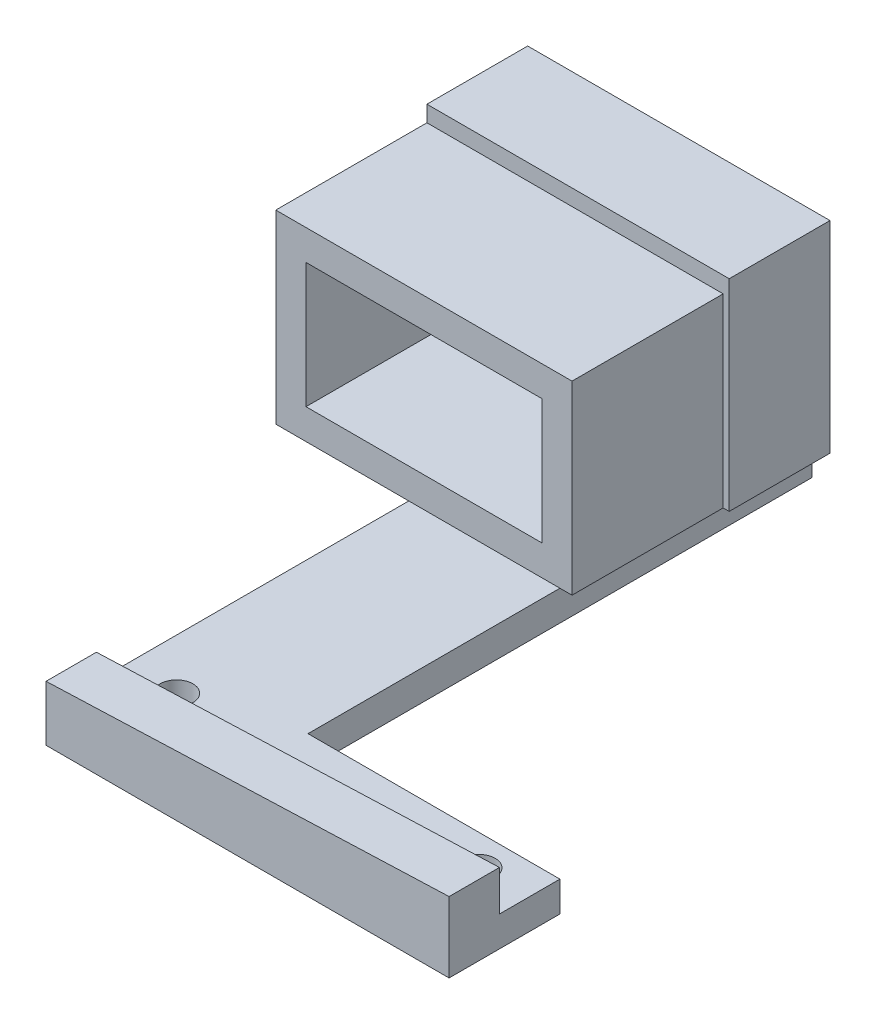
from build123d import *

# Parameters (mm, degrees)
ESQUISSE1_W             = 40
ESQUISSE1_H             = 7
BOSS_EXTRU_1_DEPTH      = 5
ENL_V_MAT_EXTRU_2_DEPTH = 6
ESQUISSE4_W             = 40
ESQUISSE4_H             = 3
BOSS_EXTRU_2_DEPTH      = 6
ESQUISSE5_R             = 1.625
ENL_V_MAT_EXTRU_3_DEPTH = 6
ESQUISSE6_W             = 15
ESQUISSE6_H             = 3
BOSS_EXTRU_3_DEPTH      = 50
ESQUISSE7_W             = 10
ESQUISSE7_H             = 3
BOSS_EXTRU_4_DEPTH      = 13.2
ESQUISSE8_W             = 30
ESQUISSE8_H             = 10
BOSS_EXTRU_5_DEPTH      = 20
ESQUISSE9_W             = 29.4
ESQUISSE9_H             = 18.4
ESQUISSE9_W_2           = 23.4
ESQUISSE9_H_2           = 12.4
BOSS_EXTRU_6_DEPTH      = 15
ESQUISSE11_W            = 10
ESQUISSE11_H            = 5
ENL_V_MAT_EXTRU_5_DEPTH = 15


with BuildPart() as part:
    # Esquisse1 → Boss.-Extru.1 (new body)
    with BuildSketch(Plane.XY):
        with Locations((20, -3.5)):
            Rectangle(ESQUISSE1_W, ESQUISSE1_H)
    extrude(amount=BOSS_EXTRU_1_DEPTH)

    # Esquisse3 → Enlèv. mat.-Extru.2 (cut, through all)
    with BuildSketch(Plane.XY.offset(5)):
        Polygon((40, 0), (0, 0), (0, -1.5), align=None)
    extrude(amount=-ENL_V_MAT_EXTRU_2_DEPTH, mode=Mode.SUBTRACT)

    # Esquisse4 → Boss.-Extru.2 (add)
    with BuildSketch(Plane(origin=(0, 0, 0), x_dir=(-1, 0, 0), z_dir=(0, 0, -1))):
        with Locations((-20, -5.5)):
            Rectangle(ESQUISSE4_W, ESQUISSE4_H)
    extrude(amount=BOSS_EXTRU_2_DEPTH)

    # Esquisse5 → Enlèv. mat.-Extru.3 (cut)
    with BuildSketch(Plane(origin=(0, -4, 0), x_dir=(1, 0, 0), z_dir=(0, 1, 0))):
        with Locations((35, 2.949699752)):
            Circle(ESQUISSE5_R)
        with Locations((5, 2.949699752)):
            Circle(ESQUISSE5_R)
    extrude(amount=-ENL_V_MAT_EXTRU_3_DEPTH, mode=Mode.SUBTRACT)

    # Esquisse6 → Boss.-Extru.3 (add)
    with BuildSketch(Plane(origin=(0, 0, -6), x_dir=(-1, 0, 0), z_dir=(0, 0, -1))):
        with Locations((-7.5, -5.5)):
            Rectangle(ESQUISSE6_W, ESQUISSE6_H)
    extrude(amount=BOSS_EXTRU_3_DEPTH)

    # Esquisse7 → Boss.-Extru.4 (add)
    with BuildSketch(Plane.ZY):
        with Locations((-51, -5.5)):
            Rectangle(ESQUISSE7_W, ESQUISSE7_H)
    extrude(amount=BOSS_EXTRU_4_DEPTH)

    # Esquisse8 → Boss.-Extru.5 (add)
    with BuildSketch(Plane(origin=(0, -4, 0), x_dir=(1, 0, 0), z_dir=(0, 1, 0))):
        with Locations((1.8, 51)):
            Rectangle(ESQUISSE8_W, ESQUISSE8_H)
    extrude(amount=BOSS_EXTRU_5_DEPTH)

    # Esquisse9 → Boss.-Extru.6 (add)
    with BuildSketch(Plane.XY.offset(-46)):
        with Locations((1.5, 5.2)):
            Rectangle(ESQUISSE9_W, ESQUISSE9_H)
        with Locations((1.5, 5.2)):
            Rectangle(ESQUISSE9_W_2, ESQUISSE9_H_2, mode=Mode.SUBTRACT)
    extrude(amount=BOSS_EXTRU_6_DEPTH)

    # Esquisse11 → Enlèv. mat.-Extru.5 (cut)
    with BuildSketch(Plane(origin=(0, 0, -56), x_dir=(-1, 0, 0), z_dir=(0, 0, -1))):
        with Locations((8.2, 5.5)):
            Rectangle(ESQUISSE11_W, ESQUISSE11_H)
    extrude(amount=-ENL_V_MAT_EXTRU_5_DEPTH, mode=Mode.SUBTRACT)


solid = part.part
